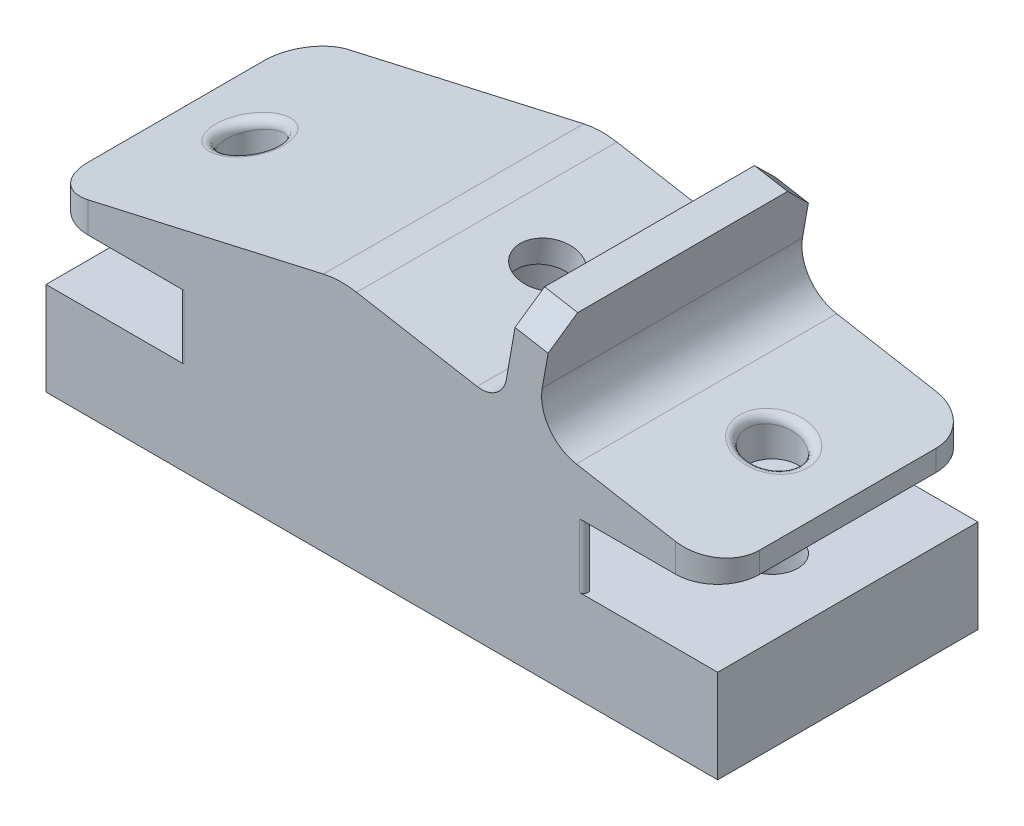
from build123d import *

# Parameters (mm, degrees)
SKETCH1_W           = 80
SKETCH1_H           = 31
SKETCH1_R           = 6
BOSS_EXTRUDE1_DEPTH = 6
SKETCH2_W           = 80
SKETCH2_H           = 31
SKETCH2_R           = 3.05
BOSS_EXTRUDE2_DEPTH = 5.9
BOSS_EXTRUDE3_DEPTH = 6.8
FILLET1_R           = 0.5
SKETCH4_W           = 80
SKETCH4_H           = 31
SKETCH4_R           = 3.05
BOSS_EXTRUDE4_DEPTH = 2.5
BOSS_EXTRUDE5_DEPTH = 31
SKETCH6_R           = 3.3
CUT_EXTRUDE1_DEPTH  = 48
SKETCH7_R           = 7.8
CUT_EXTRUDE2_DEPTH  = 47
BOSS_EXTRUDE6_DEPTH = 31
FILLET2_R           = 3
FILLET3_R           = 5
CHAMFER1_SIZE       = 3
FILLET4_R           = 5
FILLET5_R           = 10
SKETCH9_R           = 3.05
CUT_EXTRUDE3_DEPTH  = 32.549910473
FILLET6_R           = 1
CUT_EXTRUDE4_DEPTH  = 0.8


with BuildPart() as part:
    # Sketch1 → Boss-Extrude1 (new body)
    with BuildSketch(Plane(origin=(0, 0, 0), x_dir=(1, 0, 0), z_dir=(0, 1, 0))):
        Rectangle(SKETCH1_W, SKETCH1_H)
        with Locations((-31, 0)):
            Circle(SKETCH1_R, mode=Mode.SUBTRACT)
        with Locations((31, 0)):
            Circle(SKETCH1_R, mode=Mode.SUBTRACT)
    extrude(amount=BOSS_EXTRUDE1_DEPTH)

    # Sketch2 → Boss-Extrude2 (add)
    with BuildSketch(Plane(origin=(0, 6, 0), x_dir=(1, 0, 0), z_dir=(0, 1, 0))):
        Rectangle(SKETCH2_W, SKETCH2_H)
        with Locations((-31, 0)):
            Circle(SKETCH2_R, mode=Mode.SUBTRACT)
        with Locations((31, 0)):
            Circle(SKETCH2_R, mode=Mode.SUBTRACT)
    extrude(amount=BOSS_EXTRUDE2_DEPTH)

    # Sketch3 → Boss-Extrude3 (add)
    with BuildSketch(Plane(origin=(0, 11.9, 0), x_dir=(1, 0, 0), z_dir=(0, 1, 0))):
        with BuildLine():
            ThreePointArc((26.120194676, -15.5), (14.75, 0), (26.120194676, 15.5))
            Line((26.120194676, 15.5), (-26.120194676, 15.5))
            ThreePointArc((-26.120194676, 15.5), (-17.897341176, 9.611598813), (-14.75, 0))
            ThreePointArc((-14.75, 0), (-17.897341176, -9.611598813), (-26.120194676, -15.5))
            Line((-26.120194676, -15.5), (26.120194676, -15.5))
        make_face()
    extrude(amount=BOSS_EXTRUDE3_DEPTH)

    # Fillet1
    fillet1_edges = [part.edges().sort_by_distance(p)[0] for p in [
        (26.120194676, 15.3, 15.5),
        (26.120194676, 15.3, -15.5),
        (-26.120194676, 15.3, -15.5),
        (-26.120194676, 15.3, 15.5),
    ]]
    fillet(fillet1_edges, radius=FILLET1_R)

    # Sketch4 → Boss-Extrude4 (add)
    with BuildSketch(Plane(origin=(0, 18.7, 0), x_dir=(1, 0, 0), z_dir=(0, 1, 0))):
        Rectangle(SKETCH4_W, SKETCH4_H)
        with Locations((-31, 0)):
            Circle(SKETCH4_R, mode=Mode.SUBTRACT)
        with Locations((31, 0)):
            Circle(SKETCH4_R, mode=Mode.SUBTRACT)
    extrude(amount=BOSS_EXTRUDE4_DEPTH)

    # Sketch5 → Boss-Extrude5 (add)
    with BuildSketch(Plane.XY.offset(15.5)):
        Polygon((40, 21.2), (-5, 29.134714132), (-40, 21.2), align=None)
    extrude(amount=-BOSS_EXTRUDE5_DEPTH)

    # Sketch6 → Cut-Extrude1 (cut)
    with BuildSketch(Plane(origin=(4.831561104, 27.401144647, 0), x_dir=(0.984807753, -0.173648178, 0), z_dir=(0.173648178, 0.984807753, 0))):
        with Locations((-0.60768988, 0)):
            Circle(SKETCH6_R)
    extrude(amount=-CUT_EXTRUDE1_DEPTH, mode=Mode.SUBTRACT)

    # Sketch7 → Cut-Extrude2 (cut)
    with BuildSketch(Plane(origin=(-3.85084778, -21.839243004, 0), x_dir=(0.984807753, -0.173648178, 0), z_dir=(0.173648178, 0.984807753, 0))):
        with Locations((-0.60768988, 0)):
            Circle(SKETCH7_R)
    extrude(amount=CUT_EXTRUDE2_DEPTH, mode=Mode.SUBTRACT)

    # Sketch8 → Boss-Extrude6 (add)
    with BuildSketch(Plane.XY.offset(15.5)):
        Polygon((14.296517646, 25.732217437), (16.380295778, 37.549910473), (20.31952679, 36.855317763), (18.235748658, 25.037624726), align=None)
    extrude(amount=-BOSS_EXTRUDE6_DEPTH)

    # Fillet2
    fillet2_edges = [part.edges().sort_by_distance(p)[0] for p in [
        (14.296517646, 25.732217437, 0),
    ]]
    fillet(fillet2_edges, radius=FILLET2_R)

    # Fillet3
    fillet3_edges = [part.edges().sort_by_distance(p)[0] for p in [
        (18.235748658, 25.037624726, 0),
    ]]
    fillet(fillet3_edges, radius=FILLET3_R)

    # Chamfer1
    chamfer1_edges = [part.edges().sort_by_distance(p)[0] for p in [
        (18.349911284, 37.202614118, 15.5),
        (18.349911284, 37.202614118, -15.5),
    ]]
    chamfer(chamfer1_edges, length=CHAMFER1_SIZE)

    # Fillet4
    fillet4_edges = [part.edges().sort_by_distance(p)[0] for p in [
        (-40, 19.95, -15.5),
        (-40, 19.95, 15.5),
        (40, 19.95, 15.5),
        (40, 19.95, -15.5),
    ]]
    fillet(fillet4_edges, radius=FILLET4_R)

    # Fillet5
    fillet5_edges = [part.edges().sort_by_distance(p)[0] for p in [
        (-5, 29.134714132, 0),
    ]]
    fillet(fillet5_edges, radius=FILLET5_R)

    # Sketch9 → Cut-Extrude3 (cut, through all)
    with BuildSketch(Plane.XZ.offset(-6)):
        with Locations((-31, 0)):
            Circle(SKETCH9_R)
        with Locations((31, 0)):
            Circle(SKETCH9_R)
    extrude(amount=-CUT_EXTRUDE3_DEPTH, mode=Mode.SUBTRACT)

    # Fillet6
    fillet6_edges = [part.edges().sort_by_distance(p)[0] for p in [
        (27.95, 23.324740118, 2.44e-07),
        (-34.05, 22.548901402, 8.61e-07),
    ]]
    fillet(fillet6_edges, radius=FILLET6_R)

    # Sketch10 → Cut-Extrude4 (cut)
    with BuildSketch(Plane(origin=(0, 11.9, 0), x_dir=(1, 0, 0), z_dir=(0, 1, 0))):
        with BuildLine():
            Line((40, 15.5), (23.545974242, 15.5))
            ThreePointArc((23.545974242, 15.5), (24.032739379, 15.114279051), (23.768482474, 14.552238806))
            ThreePointArc((23.768482474, 14.552238806), (14.75, 0), (23.768482474, -14.552238806))
            ThreePointArc((23.768482474, -14.552238806), (24.032739379, -15.114279051), (23.545974242, -15.5))
            Line((23.545974242, -15.5), (40, -15.5))
            Line((40, -15.5), (40, 15.5))
        make_face()
        with BuildLine():
            Line((-40, -15.5), (-23.545974242, -15.5))
            ThreePointArc((-23.545974242, -15.5), (-24.032739379, -15.114279051), (-23.768482474, -14.552238806))
            ThreePointArc((-23.768482474, -14.552238806), (-14.75, 0), (-23.768482474, 14.552238806))
            ThreePointArc((-23.768482474, 14.552238806), (-24.032739379, 15.114279051), (-23.545974242, 15.5))
            Line((-23.545974242, 15.5), (-40, 15.5))
            Line((-40, 15.5), (-40, -15.5))
        make_face()
    extrude(amount=-CUT_EXTRUDE4_DEPTH, mode=Mode.SUBTRACT)


solid = part.part
